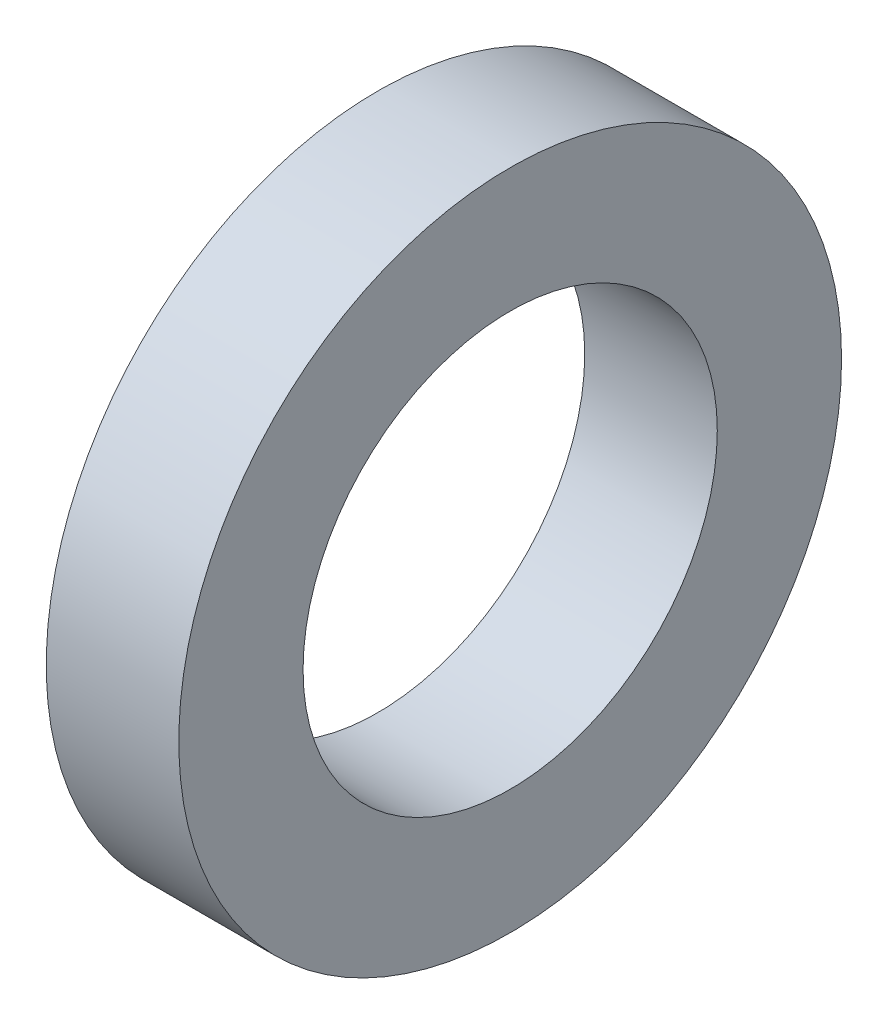
from build123d import *

# Parameters (mm, degrees)
SKETCH1_R                   = 12.7
BOSS_EXTRUDE1_DEPTH         = 5.08
F_97_0_625_DIAMETER_HOLE1_D = 15.875


with BuildPart() as part:
    # Sketch1 → Boss-Extrude1 (new body)
    with BuildSketch(Plane(origin=(0, 0, 0), x_dir=(0, 0, -1), z_dir=(1, 0, 0))):
        Circle(SKETCH1_R)
    extrude(amount=BOSS_EXTRUDE1_DEPTH)

    # #97 (0.625) Diameter Hole1 (through all)
    with Locations(Plane(origin=(5.08, 0, 0), x_dir=(0, 0, -1), z_dir=(1, 0, 0))):
        with Locations((0, 0)):
            Hole(F_97_0_625_DIAMETER_HOLE1_D / 2)


solid = part.part
